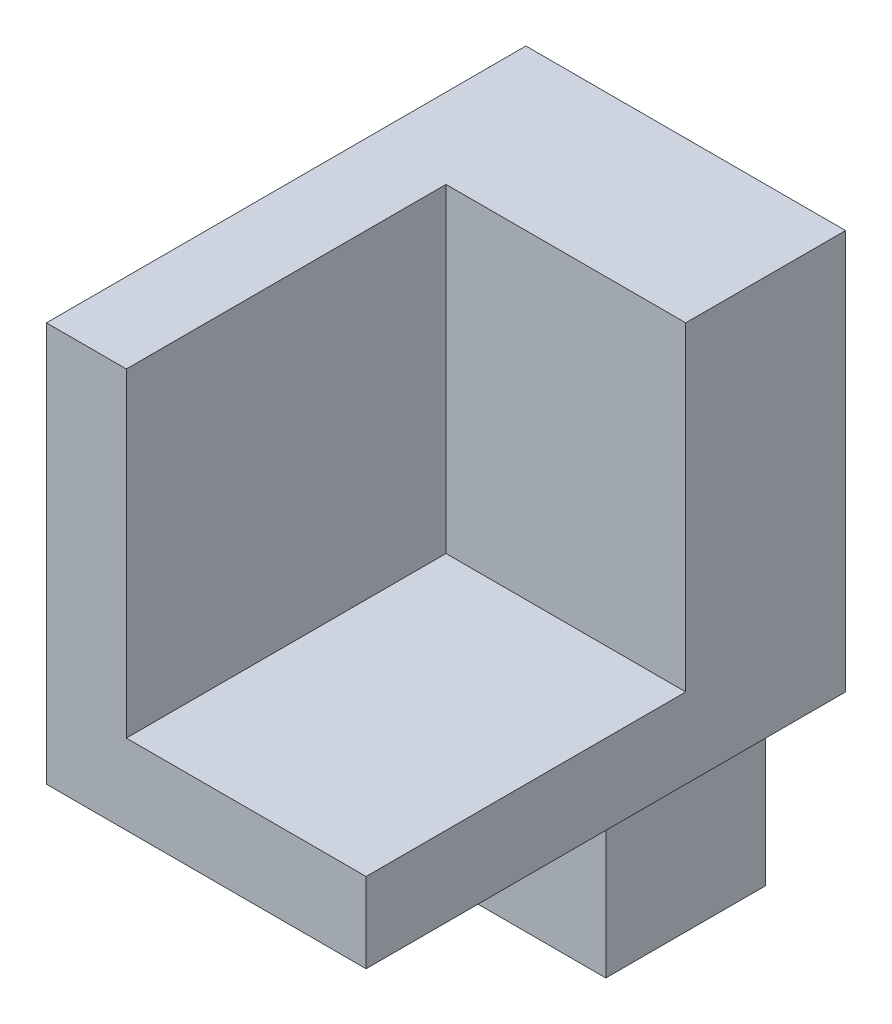
from build123d import *

# Parameters (mm, degrees)
BOSS_EXTRUDE1_DEPTH = 10
SKETCH2_W           = 30
SKETCH2_H           = 25
BOSS_EXTRUDE2_DEPTH = 5
BOSS_EXTRUDE3_DEPTH = 5


with BuildPart() as part:
    # Sketch1 → Boss-Extrude1 (new body)
    with BuildSketch(Plane(origin=(0, 0, 0), x_dir=(0, 0, -1), z_dir=(1, 0, 0))):
        Polygon((0, 0), (-10, 0), (-10, -20), (-30, -20), (-30, -25), (-10, -25), (-10, -38), (0, -38), align=None)
    extrude(amount=BOSS_EXTRUDE1_DEPTH)

    # Sketch2 → Boss-Extrude2 (add)
    with BuildSketch(Plane.ZY):
        with Locations((15, -12.5)):
            Rectangle(SKETCH2_W, SKETCH2_H)
    extrude(amount=BOSS_EXTRUDE2_DEPTH)

    # Sketch3 → Boss-Extrude3 (add)
    with BuildSketch(Plane(origin=(10, 0, 0), x_dir=(0, 0, -1), z_dir=(1, 0, 0))):
        Polygon((-10, 0), (-10, -20), (-30, -20), (-30, -25), (-10, -25), (0, -25), (0, 0), align=None)
    extrude(amount=BOSS_EXTRUDE3_DEPTH)


solid = part.part
